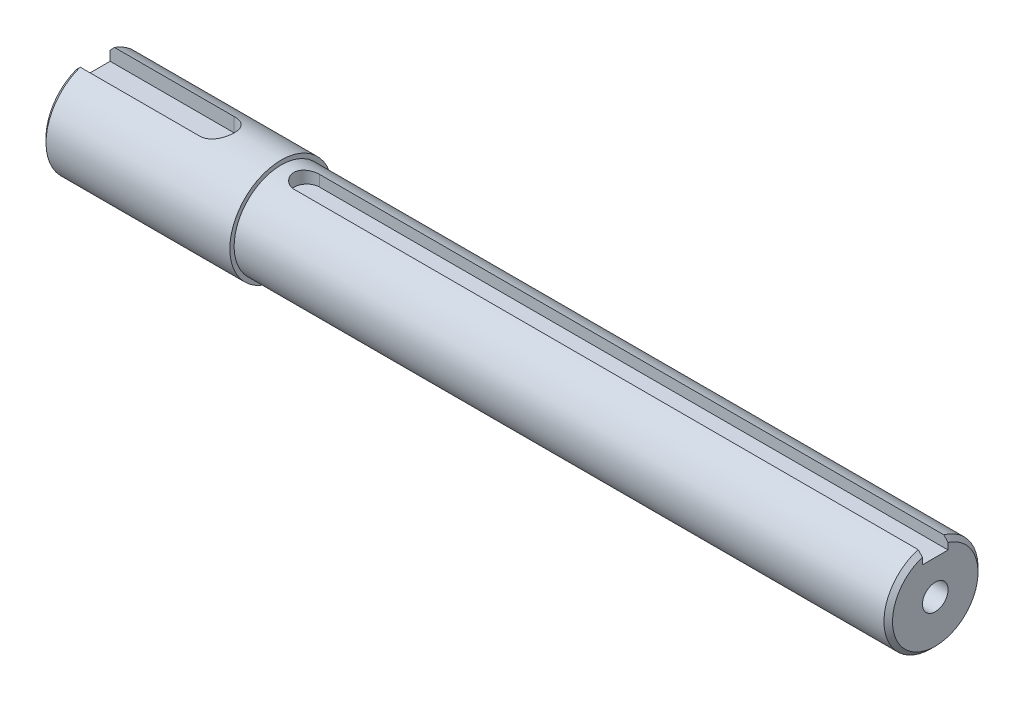
from build123d import *

# Parameters (mm, degrees)
CUT_EXTRUDE1_DEPTH = 4
CUT_EXTRUDE2_DEPTH = 3
CHAMFER1_SIZE      = 1
SKETCH4_R          = 3
CUT_EXTRUDE3_DEPTH = 20


with BuildPart() as part:
    # Sketch1 → Revolve1 (revolve)
    with BuildSketch(Plane.XY):
        Polygon((0, 0), (-197, 0), (-197, 12), (-153, 12), (-153, 11), (0, 11), align=None)
    revolve(axis=Axis((0, 0, 0), (-1, 0, 0)))

    # Sketch2 → Cut-Extrude1 (cut)
    with BuildSketch(Plane(origin=(0, 12, 0), x_dir=(1, 0, 0), z_dir=(0, 1, 0))):
        with BuildLine():
            Line((-167.997220054, 4), (-197, 4))
            Line((-197, 4), (-197, -4))
            Line((-197, -4), (-167.997221426, -4))
            ThreePointArc((-167.997221426, -4), (-163.997220054, -6.86e-07), (-167.997220054, 4))
        make_face()
    extrude(amount=-CUT_EXTRUDE1_DEPTH, mode=Mode.SUBTRACT)

    # Sketch3 → Cut-Extrude2 (cut)
    with BuildSketch(Plane(origin=(0, 11, 0), x_dir=(1, 0, 0), z_dir=(0, 1, 0))):
        with BuildLine():
            Line((-147, 3), (0, 3))
            Line((0, 3), (0, -3))
            Line((0, -3), (-147, -3))
            ThreePointArc((-147, -3), (-150, 0), (-147, 3))
        make_face()
    extrude(amount=-CUT_EXTRUDE2_DEPTH, mode=Mode.SUBTRACT)

    # Chamfer1
    chamfer1_edges = [part.edges().sort_by_distance(p)[0] for p in [
        (-197, -12, 0),
        (0, -11, 0),
    ]]
    chamfer(chamfer1_edges, length=CHAMFER1_SIZE)

    # Sketch4 → Cut-Extrude3 (cut)
    with BuildSketch(Plane(origin=(0, 0, 0), x_dir=(0, 0, -1), z_dir=(1, 0, 0))):
        Circle(SKETCH4_R)
    extrude(amount=-CUT_EXTRUDE3_DEPTH, mode=Mode.SUBTRACT)


solid = part.part
